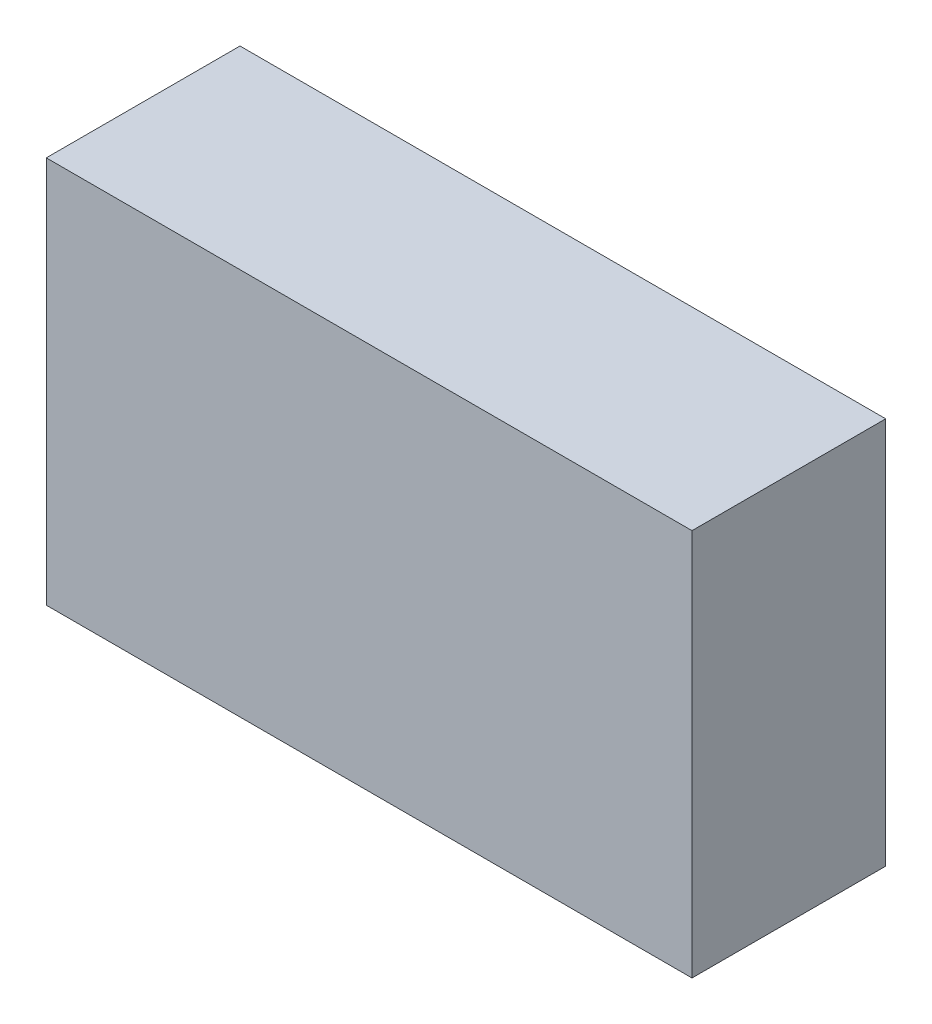
from build123d import *

# Parameters (mm, degrees)
SKETCH1_W           = 20
SKETCH1_H           = 12
BOSS_EXTRUDE1_DEPTH = 6


with BuildPart() as part:
    # Sketch1 → Boss-Extrude1 (new body)
    with BuildSketch(Plane.XY):
        Rectangle(SKETCH1_W, SKETCH1_H)
    extrude(amount=BOSS_EXTRUDE1_DEPTH)


solid = part.part
